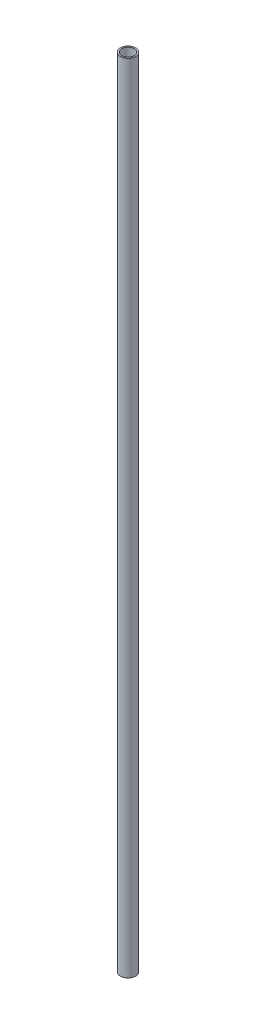
from build123d import *

# Parameters (mm, degrees)
SKETCH1_W = 0.889
SKETCH1_H = 500


with BuildPart() as part:
    # Sketch1 → Revolve1 (revolve)
    with BuildSketch(Plane.XY):
        with Locations((4.318, 250)):
            Rectangle(SKETCH1_W, SKETCH1_H)
    revolve(axis=Axis((0, 0, 0), (0, 1, 0)))


solid = part.part
